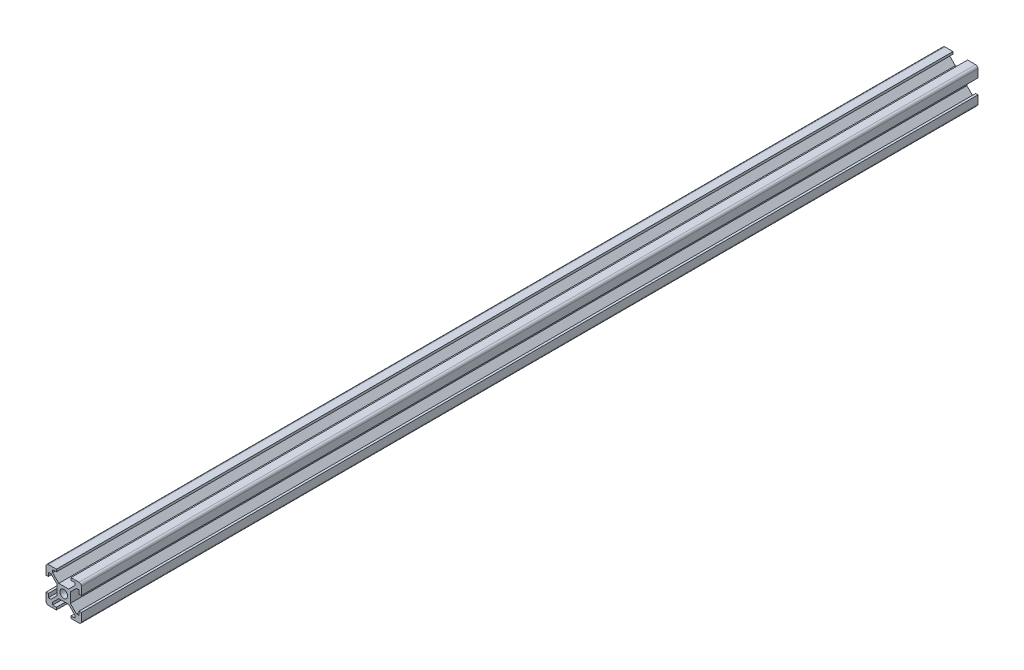
from build123d import *

# Parameters (mm, degrees)
SKETCH_1_R      = 1.65
EXTRUDE_1_DEPTH = 380


with BuildPart() as part:
    # 草图1 → 凸台-拉伸1 (new body)
    with BuildSketch(Plane.XY):
        with BuildLine():
            Line((-2.092893219, 2.8), (2.092893219, 2.8))
            Line((2.092893219, 2.8), (4.7, 5.407106781))
            Line((4.7, 5.407106781), (4.7, 6.5))
            Line((4.7, 6.5), (3.1, 6.5))
            Line((3.1, 6.5), (3.1, 7.5))
            Line((3.1, 7.5), (6.5, 7.5))
            ThreePointArc((6.5, 7.5), (7.207106781, 7.207106781), (7.5, 6.5))
            Line((7.5, 6.5), (7.5, 3.1))
            Line((7.5, 3.1), (6.5, 3.1))
            Line((6.5, 3.1), (6.5, 4.7))
            Line((6.5, 4.7), (5.407106781, 4.7))
            Line((5.407106781, 4.7), (2.8, 2.092893219))
            Line((2.8, 2.092893219), (2.8, -2.092893219))
            Line((2.8, -2.092893219), (5.407106781, -4.7))
            Line((5.407106781, -4.7), (6.5, -4.7))
            Line((6.5, -4.7), (6.5, -3.1))
            Line((6.5, -3.1), (7.5, -3.1))
            Line((7.5, -3.1), (7.5, -6.5))
            ThreePointArc((7.5, -6.5), (7.207106781, -7.207106781), (6.5, -7.5))
            Line((6.5, -7.5), (3.1, -7.5))
            Line((3.1, -7.5), (3.1, -6.5))
            Line((3.1, -6.5), (4.7, -6.5))
            Line((4.7, -6.5), (4.7, -5.407106781))
            Line((4.7, -5.407106781), (2.092893219, -2.8))
            Line((2.092893219, -2.8), (-2.092893219, -2.8))
            Line((-2.092893219, -2.8), (-4.7, -5.407106781))
            Line((-4.7, -5.407106781), (-4.7, -6.5))
            Line((-4.7, -6.5), (-3.1, -6.5))
            Line((-3.1, -6.5), (-3.1, -7.5))
            Line((-3.1, -7.5), (-6.5, -7.5))
            ThreePointArc((-6.5, -7.5), (-7.207106781, -7.207106781), (-7.5, -6.5))
            Line((-7.5, -6.5), (-7.5, -3.1))
            Line((-7.5, -3.1), (-6.5, -3.1))
            Line((-6.5, -3.1), (-6.5, -4.7))
            Line((-6.5, -4.7), (-5.407106781, -4.7))
            Line((-5.407106781, -4.7), (-2.8, -2.092893219))
            Line((-2.8, -2.092893219), (-2.8, 2.092893219))
            Line((-2.8, 2.092893219), (-5.407106781, 4.7))
            Line((-5.407106781, 4.7), (-6.5, 4.7))
            Line((-6.5, 4.7), (-6.5, 3.1))
            Line((-6.5, 3.1), (-7.5, 3.1))
            Line((-7.5, 3.1), (-7.5, 6.5))
            ThreePointArc((-7.5, 6.5), (-7.207106781, 7.207106781), (-6.5, 7.5))
            Line((-6.5, 7.5), (-3.1, 7.5))
            Line((-3.1, 7.5), (-3.1, 6.5))
            Line((-3.1, 6.5), (-4.7, 6.5))
            Line((-4.7, 6.5), (-4.7, 5.407106781))
            Line((-4.7, 5.407106781), (-2.092893219, 2.8))
        make_face()
        Circle(SKETCH_1_R, mode=Mode.SUBTRACT)
    extrude(amount=EXTRUDE_1_DEPTH)


solid = part.part
